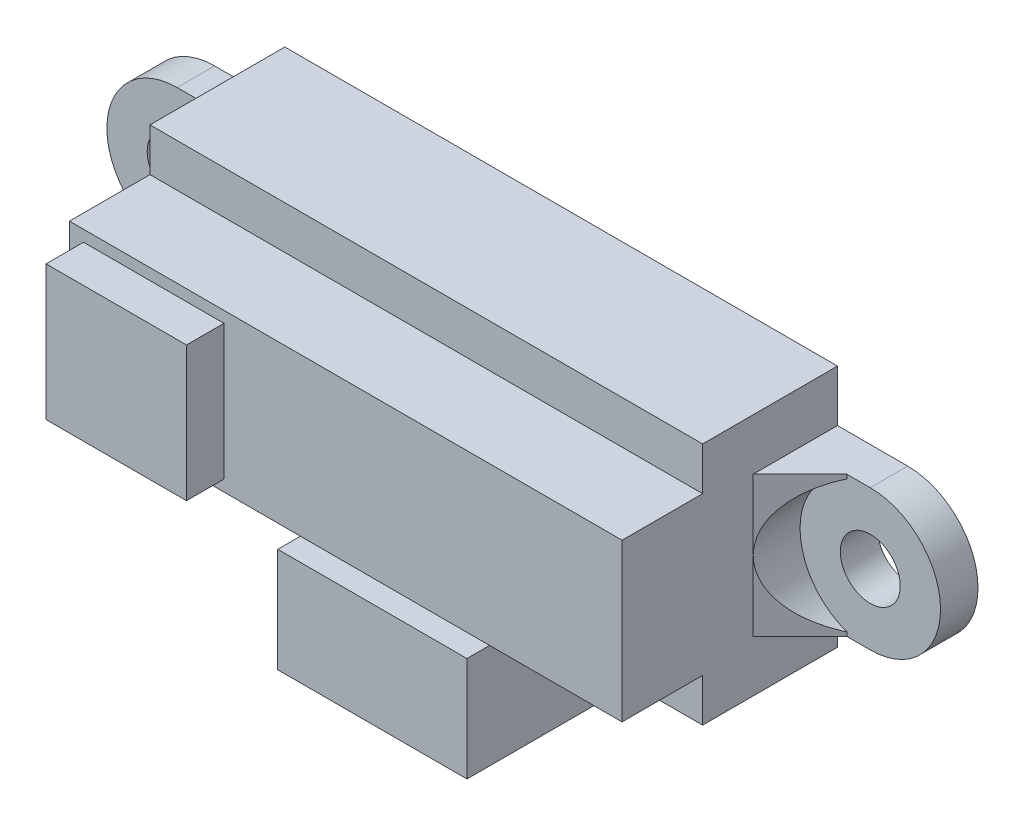
from build123d import *

# Parameters (mm, degrees)
ESQUISSE1_W                         = 29.5
ESQUISSE1_H                         = 13
BOSS_EXTRU_1_DEPTH                  = 11.5
ESQUISSE2_W                         = 4.3
ESQUISSE2_H                         = 2.3
ENL_V_MAT_EXTRU_1_DEPTH             = 30.5
ESQUISSE3_W                         = 4.3
ESQUISSE3_H                         = 2.3
ENL_V_MAT_EXTRU_2_DEPTH             = 30.5
BOSS_EXTRU_2_DEPTH                  = 2
BOSS_EXTRU_3_DEPTH                  = 2
ESQUISSE6_W                         = 7.5
ESQUISSE6_H                         = 7.2
BOSS_EXTRU_4_DEPTH                  = 2
DIAM_TRE_DU_PER_AGE_3_2_3_2_1_D     = 3.2
DIAM_TRE_DU_PER_AGE_3_2_3_2_1_DEPTH = 13.5
BOSS_EXTRU_5_DEPTH                  = 5.05
BOSS_EXTRU_5_DEPTH_BACK             = 5.05
BOSS_EXTRU_6_DEPTH                  = 7.5
ESQUISSE11_R                        = 3.75
ENL_V_MAT_EXTRU_3_DEPTH             = 9.5


with BuildPart() as part:
    # Esquisse1 → Boss.-Extru.1 (new body)
    with BuildSketch(Plane.XY.offset(11.5)):
        Rectangle(ESQUISSE1_W, ESQUISSE1_H)
    extrude(amount=-BOSS_EXTRU_1_DEPTH)

    # Esquisse2 → Enlèv. mat.-Extru.1 (cut, through all)
    with BuildSketch(Plane(origin=(14.75, 0, 0), x_dir=(0, 0, -1), z_dir=(1, 0, 0))):
        with Locations((-9.35, -5.35)):
            Rectangle(ESQUISSE2_W, ESQUISSE2_H)
    extrude(amount=-ENL_V_MAT_EXTRU_1_DEPTH, mode=Mode.SUBTRACT)

    # Esquisse3 → Enlèv. mat.-Extru.2 (cut, through all)
    with BuildSketch(Plane(origin=(14.75, 0, 0), x_dir=(0, 0, -1), z_dir=(1, 0, 0))):
        with Locations((-9.35, 5.35)):
            Rectangle(ESQUISSE3_W, ESQUISSE3_H)
    extrude(amount=-ENL_V_MAT_EXTRU_2_DEPTH, mode=Mode.SUBTRACT)

    # Esquisse4 → Boss.-Extru.2 (add)
    with BuildSketch(Plane(origin=(0, 0, 0), x_dir=(-1, 0, 0), z_dir=(0, 0, -1))):
        with BuildLine():
            Line((-14.75, -3.75), (-14.75, 3.75))
            Line((-14.75, 3.75), (-18.5, 3.75))
            ThreePointArc((-18.5, 3.75), (-22.25, 0), (-18.5, -3.75))
            Line((-18.5, -3.75), (-14.75, -3.75))
        make_face()
    extrude(amount=-BOSS_EXTRU_2_DEPTH)

    # Esquisse5 → Boss.-Extru.3 (add)
    with BuildSketch(Plane(origin=(0, 0, 0), x_dir=(-1, 0, 0), z_dir=(0, 0, -1))):
        with BuildLine():
            Line((18.5, 3.75), (14.75, 3.75))
            Line((14.75, 3.75), (14.75, -3.75))
            Line((14.75, -3.75), (18.5, -3.75))
            ThreePointArc((18.5, -3.75), (22.25, 0), (18.5, 3.75))
        make_face()
    extrude(amount=-BOSS_EXTRU_3_DEPTH)

    # Esquisse6 → Boss.-Extru.4 (add)
    with BuildSketch(Plane.XY.offset(11.5)):
        with Locations((-10.25, 0)):
            Rectangle(ESQUISSE6_W, ESQUISSE6_H)
    extrude(amount=BOSS_EXTRU_4_DEPTH)

    # Diamètre du perçage Ø3.2 (3.2)1
    with Locations(Plane(origin=(0, 0, 0), x_dir=(-1, 0, 0), z_dir=(0, 0, -1))):
        with Locations((-18.5, 0), (18.5, 0)):
            Hole(DIAM_TRE_DU_PER_AGE_3_2_3_2_1_D / 2, depth=DIAM_TRE_DU_PER_AGE_3_2_3_2_1_DEPTH)

    # Esquisse9 → Boss.-Extru.5 (add, two sides)
    with BuildSketch(Plane(origin=(0, 0, 0), x_dir=(0, 0, -1), z_dir=(1, 0, 0))) as boss_extru_5_sk:
        Polygon((-8.51, -6.83), (-10.08, -6.83), (-10.08, -12.4), (-3.3, -12.4), (-3.3, -6.5), (-7.2, -6.5), (-7.2, -5.964667694), align=None)
    extrude(amount=BOSS_EXTRU_5_DEPTH)
    extrude(boss_extru_5_sk.sketch, amount=-BOSS_EXTRU_5_DEPTH_BACK)

    # Esquisse10 → Boss.-Extru.6 (add)
    with BuildSketch(Plane(origin=(0, 3.75, 0), x_dir=(1, 0, 0), z_dir=(0, 1, 0))):
        Polygon((14.75, -2), (14.75, -4.5), (17.25, -2), align=None)
        Polygon((-14.75, -2), (-14.75, -4.5), (-17.25, -2), align=None)
    extrude(amount=-BOSS_EXTRU_6_DEPTH)

    # Esquisse11 → Enlèv. mat.-Extru.3 (cut)
    with BuildSketch(Plane.XY.offset(11.5)):
        with Locations((18.5, 0)):
            Circle(ESQUISSE11_R)
        with Locations((-18.5, 0)):
            Circle(ESQUISSE11_R)
    extrude(amount=-ENL_V_MAT_EXTRU_3_DEPTH, mode=Mode.SUBTRACT)


solid = part.part
